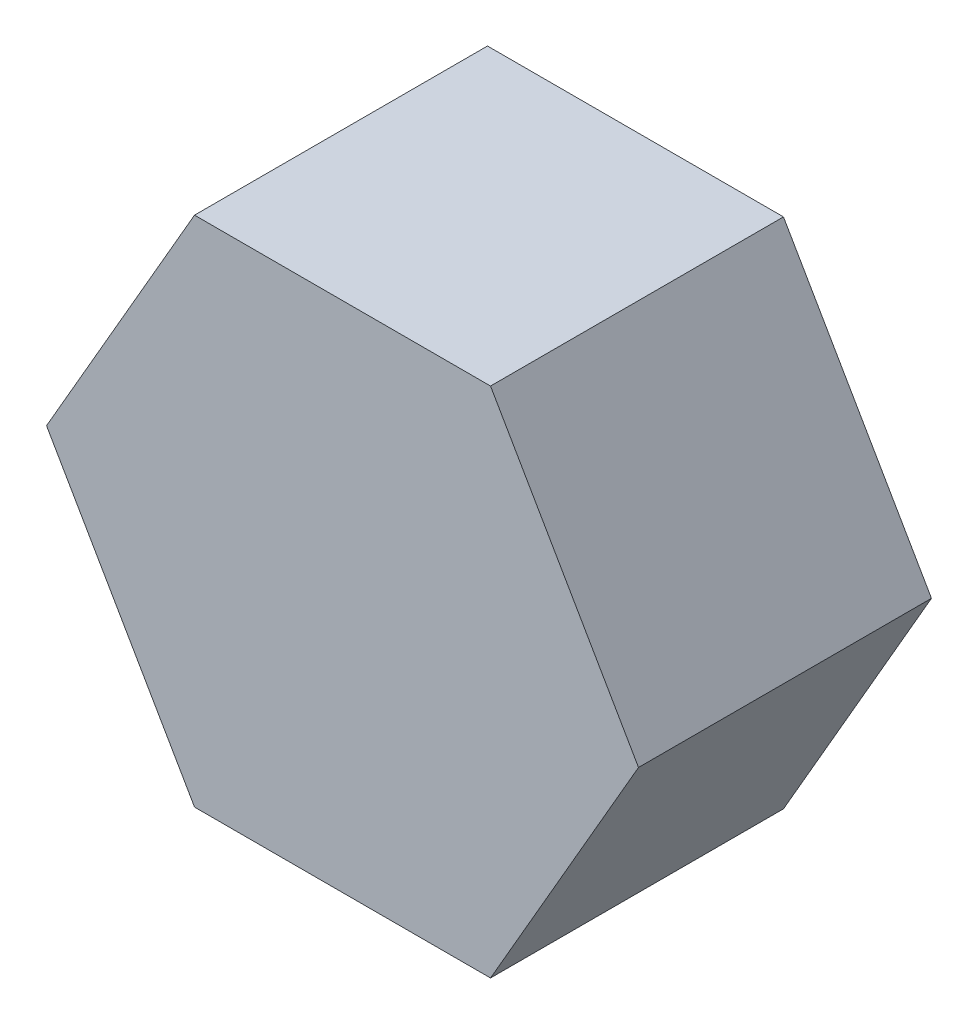
from build123d import *

# Parameters (mm, degrees)
BOSS_EXTRUDE1_DEPTH = 8


with BuildPart() as part:
    # Sketch1 → Boss-Extrude1 (new body)
    with BuildSketch(Plane.XY):
        Polygon((-8.082903769, 0), (-4.041451884, -7), (4.041451884, -7), (8.082903769, 0), (4.041451884, 7), (-4.041451884, 7), align=None)
    extrude(amount=BOSS_EXTRUDE1_DEPTH)


solid = part.part
